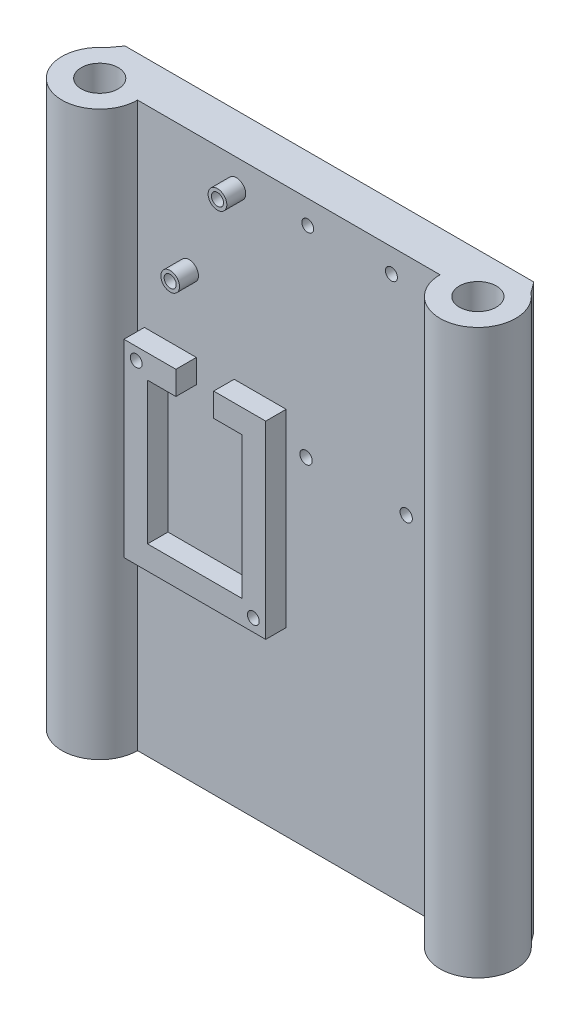
from build123d import *

# Parameters (mm, degrees)
SKETCH1_R           = 4.9609375
BOSS_EXTRUDE1_DEPTH = 75.692
SKETCH3_R           = 1.6256
CUT_EXTRUDE1_DEPTH  = 98.798395582
BOSS_EXTRUDE2_START = 5.08
SKETCH3_3_R         = 2.511415146
SKETCH3_3_R_2       = 1.6256
BOSS_EXTRUDE2_DEPTH = 5.08
SKETCH4_R           = 1.580559699
SKETCH4_R_2         = 1.615968851
SKETCH4_R_3         = 1.651
CUT_EXTRUDE2_DEPTH  = 98.798395582
BOSS_EXTRUDE3_DEPTH = 5.500116
SKETCH6_R           = 1.5875
CUT_EXTRUDE3_DEPTH  = 99.563883783


with BuildPart() as part:
    # Sketch1 → Boss-Extrude1 (new, symmetric)
    with BuildSketch(Plane(origin=(0, 0, 0), x_dir=(1, 0, 0), z_dir=(0, 1, 0))):
        with BuildLine():
            ThreePointArc((-54.898232946, 10.914472708), (-55.979756859, 9.486084273), (-57.024125462, 8.030308975))
            ThreePointArc((-57.024125462, 8.030308975), (-55.271492218, -9.123122127), (-40.64, 0))
            Line((-40.64, 0), (40.64, 0))
            ThreePointArc((40.64, 0), (55.271492218, -9.123122127), (57.024125462, 8.030308975))
            ThreePointArc((57.024125462, 8.030308975), (55.979756859, 9.486084273), (54.898232946, 10.914472708))
            Line((54.898232946, 10.914472708), (-54.898232946, 10.914472708))
        make_face()
        with Locations((-50.8, 0)):
            Circle(SKETCH1_R, mode=Mode.SUBTRACT)
        with Locations((50.8, 0)):
            Circle(SKETCH1_R, mode=Mode.SUBTRACT)
    extrude(amount=BOSS_EXTRUDE1_DEPTH, both=True)

    # Sketch3 → Cut-Extrude1 (cut, through all)
    with BuildSketch(Plane.XY):
        with Locations((-14.08707582, 68.405041605)):
            Circle(SKETCH3_R)
        with Locations((-26.78707582, 43.005041605)):
            Circle(SKETCH3_R)
    extrude(amount=-CUT_EXTRUDE1_DEPTH, mode=Mode.SUBTRACT)

    # Sketch3_3 → Boss-Extrude2 (add)
    # profile 1 of 2: a face of its own
    with BuildSketch(Plane.XY.offset(BOSS_EXTRUDE2_START)):
        with Locations((-14.08707582, 68.405041605)):
            Circle(SKETCH3_3_R)
        with Locations((-14.08707582, 68.405041605)):
            Circle(SKETCH3_3_R_2, mode=Mode.SUBTRACT)
    # profile 2 of 2: a face of its own
    with BuildSketch(Plane.XY.offset(BOSS_EXTRUDE2_START)):
        with Locations((-26.78707582, 43.005041605)):
            Circle(SKETCH3_3_R)
        with Locations((-26.78707582, 43.005041605)):
            Circle(SKETCH3_3_R_2, mode=Mode.SUBTRACT)
    extrude(amount=-BOSS_EXTRUDE2_DEPTH)

    # Sketch4 → Cut-Extrude2 (cut, through all)
    with BuildSketch(Plane.XY):
        with Locations((5.097142458, 69.338036856)):
            Circle(SKETCH4_R)
        with Locations((27.569466172, 69.326708036)):
            Circle(SKETCH4_R_2)
        with Locations((4.630258258, 15.178805596)):
            Circle(SKETCH4_R_3)
        with Locations((31.55425332, 15.195112998)):
            Circle(SKETCH4_R_3)
    extrude(amount=-CUT_EXTRUDE2_DEPTH, mode=Mode.SUBTRACT)

    # Sketch5 → Boss-Extrude3 (add)
    with BuildSketch(Plane.XY):
        Polygon((-32.457787853, 17.360692428), (-24.837787853, 17.360692428), (-24.837787853, 23.710692428), (-38.807787853, 23.710692428), (-38.807787853, -27.089307572), (-0.707787853, -27.089307572), (-0.707787853, 23.710692428), (-14.677787853, 23.710692428), (-14.677787853, 17.360692428), (-7.057787853, 17.360692428), (-7.057787853, -20.739307572), (-32.457787853, -20.739307572), align=None)
    extrude(amount=BOSS_EXTRUDE3_DEPTH)

    # Sketch6 → Cut-Extrude3 (cut, through all)
    with BuildSketch(Plane.XY.offset(5.500116)):
        with Locations((-35.482909848, 20.385814423)):
            Circle(SKETCH6_R)
        with Locations((-4.032665858, -23.764429567)):
            Circle(SKETCH6_R)
    extrude(amount=-CUT_EXTRUDE3_DEPTH, mode=Mode.SUBTRACT)


solid = part.part
